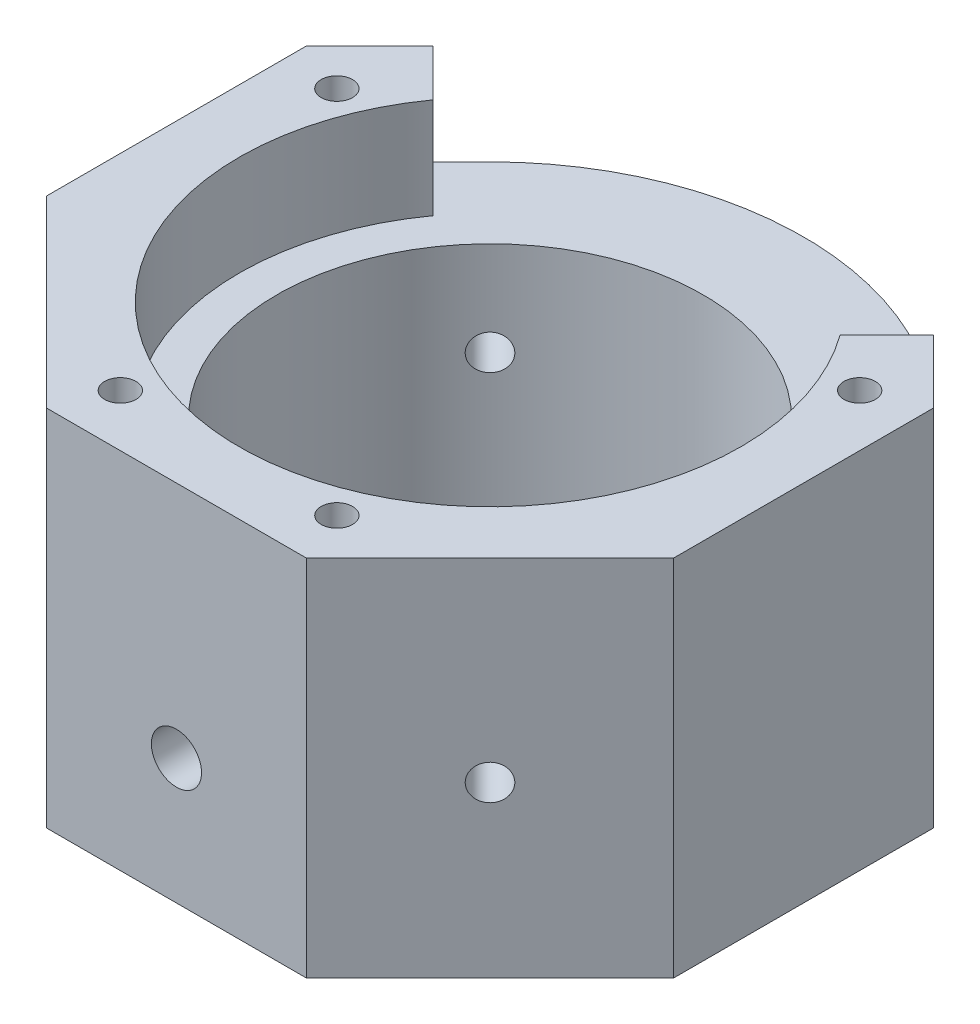
from build123d import *

# Parameters (mm, degrees)
SKETCH1_R                 = 17
BOSS_EXTRUDE1_DEPTH       = 21
SKETCH2_R                 = 20
BOSS_EXTRUDE2_DEPTH       = 8
CUT_EXTRUDE3_DEPTH        = 8
M3_TAPPED_HOLE1_D         = 2.5
M3_TAPPED_HOLE1_DEPTH     = 10
M3_TAPPED_HOLE1_TIP       = 0.751075774
F_4_40_TAPPED_HOLE1_D     = 2.2606
F_4_40_TAPPED_HOLE1_DEPTH = 5
F_4_40_TAPPED_HOLE1_TIP   = 0.679152758
M3X0_2_TAPPED_HOLE1_D     = 2.8
M3X0_2_TAPPED_HOLE2_D     = 2.8
CUT_EXTRUDE4_REACH        = 52
SKETCH20_R                = 2
CUT_EXTRUDE5_DEPTH        = 12


with BuildPart() as part:
    # Sketch1 → Boss-Extrude1 (new body)
    with BuildSketch(Plane(origin=(0, 0, 0), x_dir=(1, 0, 0), z_dir=(0, 1, 0))):
        Polygon((10.355339059, 25), (-10.355339059, 25), (-25, 10.355339059), (-25, -10.355339059), (-10.355339059, -25), (10.355339059, -25), (25, -10.355339059), (25, 10.355339059), align=None)
        Circle(SKETCH1_R, mode=Mode.SUBTRACT)
    extrude(amount=BOSS_EXTRUDE1_DEPTH)

    # Sketch2 → Boss-Extrude2 (add)
    with BuildSketch(Plane(origin=(0, 21, 0), x_dir=(1, 0, 0), z_dir=(0, 1, 0))):
        Polygon((25, 10.355339059), (10.355339059, 25), (-10.355339059, 25), (-25, 10.355339059), (-25, -10.355339059), (-10.355339059, -25), (10.355339059, -25), (25, -10.355339059), align=None)
        Circle(SKETCH2_R, mode=Mode.SUBTRACT)
    extrude(amount=BOSS_EXTRUDE2_DEPTH)

    # Sketch6 → Cut-Extrude3 (cut)
    with BuildSketch(Plane(origin=(0, 29, 0), x_dir=(1, 0, 0), z_dir=(0, 1, 0))):
        Polygon((-19.940411229, 15.41492783), (-16.222684393, 11.697200993), (16.222684393, 11.697200993), (19.940411229, 15.41492783), (10.355339059, 25), (-10.355339059, 25), align=None)
    extrude(amount=-CUT_EXTRUDE3_DEPTH, mode=Mode.SUBTRACT)

    # M3 Tapped Hole1
    with Locations(Plane(origin=(0, 29, 0), x_dir=(1, 0, 0), z_dir=(0, 1, 0))):
        with Locations((20.842542104, 8.633263614), (-20.842542104, 8.633263614), (-8.633263614, -20.842542104), (8.633263614, -20.842542104)):
            Hole(M3_TAPPED_HOLE1_D / 2, depth=M3_TAPPED_HOLE1_DEPTH)
            with Locations((0, 0, -(M3_TAPPED_HOLE1_DEPTH + M3_TAPPED_HOLE1_TIP / 2))):  # 118° drill point
                Cone(0, M3_TAPPED_HOLE1_D / 2, M3_TAPPED_HOLE1_TIP, mode=Mode.SUBTRACT)

    # #4-40 Tapped Hole1
    with Locations(Plane(origin=(0, 0, 0), x_dir=(-1, 0, 0), z_dir=(0, -1, 0))):
        with Locations((-15, 15), (15, 15), (-15, -15), (15, -15)):
            Hole(F_4_40_TAPPED_HOLE1_D / 2, depth=F_4_40_TAPPED_HOLE1_DEPTH)
            with Locations((0, 0, -(F_4_40_TAPPED_HOLE1_DEPTH + F_4_40_TAPPED_HOLE1_TIP / 2))):  # 118° drill point
                Cone(0, F_4_40_TAPPED_HOLE1_D / 2, F_4_40_TAPPED_HOLE1_TIP, mode=Mode.SUBTRACT)

    # M3x0.2 Tapped Hole1 (through all)
    with Locations(Plane(origin=(17.67766953, 0, -17.67766953), x_dir=(-0.707106781, 0, -0.707106781), z_dir=(0.707106781, 0, -0.707106781))):
        with Locations((0, 11)):
            Hole(M3X0_2_TAPPED_HOLE1_D / 2)

    # M3x0.2 Tapped Hole2 (through all)
    with Locations(Plane(origin=(-17.67766953, 0, -17.67766953), x_dir=(-0.707106781, 0, 0.707106781), z_dir=(-0.707106781, 0, -0.707106781))):
        with Locations((0, 13.5)):
            Hole(M3X0_2_TAPPED_HOLE2_D / 2)

    # Sketch20 → Cut-Extrude4 (cut, up to next)
    with BuildSketch(Plane.XY.offset(25), mode=Mode.PRIVATE) as cut_extrude4_sk1:
        with Locations((0, 10)):
            Circle(SKETCH20_R)
    cut_extrude4_tool1 = extrude(cut_extrude4_sk1.sketch, amount=-CUT_EXTRUDE4_REACH, mode=Mode.PRIVATE) & part.part
    add(cut_extrude4_tool1.solids().sort_by_distance((0, 10, 25))[0], mode=Mode.SUBTRACT)

    # Sketch22 → Cut-Extrude5 (cut)
    with BuildSketch(Plane(origin=(0, 29, 0), x_dir=(1, 0, 0), z_dir=(0, 1, 0))):
        with BuildLine():
            Line((-17.67766953, 17.67766953), (-17.67766953, 26.402318696))
            Line((-17.67766953, 26.402318696), (17.67766953, 26.402318696))
            Line((17.67766953, 26.402318696), (17.67766953, 17.67766953))
            ThreePointArc((17.67766953, 17.67766953), (0, 25), (-17.67766953, 17.67766953))
        make_face()
    extrude(amount=-CUT_EXTRUDE5_DEPTH, mode=Mode.SUBTRACT)


solid = part.part
